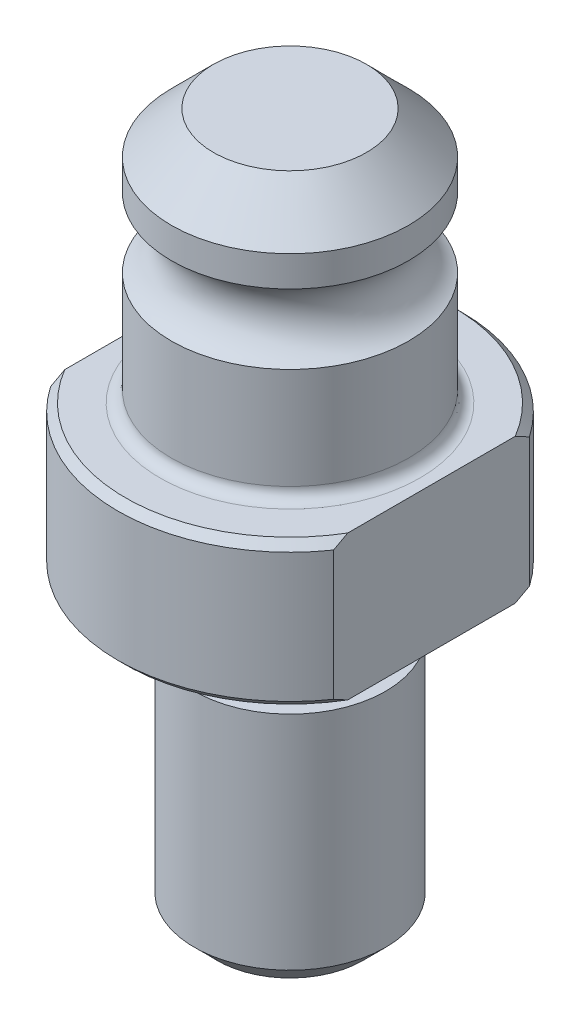
from build123d import *

# Parameters (mm, degrees)
CHAMFER1_SIZE      = 0.508
CHAMFER2_SIZE      = 1.524
CUT_EXTRUDE1_DEPTH = 30.6672
FILLET1_R          = 0.762


with BuildPart() as part:
    # Sketch1 → Revolve1 (revolve)
    with BuildSketch(Plane.XY):
        with BuildLine():
            Line((0, 26.543), (0, -20.066))
            Line((0, -20.066), (-6.35, -20.066))
            Line((-6.35, -20.066), (-6.35, -3.81))
            Line((-6.35, -3.81), (-5.1943, -3.81))
            Line((-5.1943, -3.81), (-5.1943, -1.27))
            ThreePointArc((-5.1943, -1.27), (-5.566274388, -0.371974388), (-6.4643, 0))
            Line((-6.4643, 0), (-11.43, 0))
            Line((-11.43, 0), (-11.43, 9.6012))
            Line((-11.43, 9.6012), (-7.874, 9.6012))
            Line((-7.874, 9.6012), (-7.874, 17.0942))
            ThreePointArc((-7.874, 17.0942), (-6.35, 19.4056), (-7.874, 21.717))
            Line((-7.874, 21.717), (-7.874, 23.749))
            Line((-7.874, 23.749), (-5.08, 26.543))
            Line((-5.08, 26.543), (0, 26.543))
        make_face()
    revolve(axis=Axis((0, -20.066, 0), (0, -1, 0)))

    # Chamfer1
    chamfer1_edges = [part.edges().sort_by_distance(p)[0] for p in [
        (11.43, 9.6012, 0),
        (11.43, 0, 0),
    ]]
    chamfer(chamfer1_edges, length=CHAMFER1_SIZE)

    # Chamfer2
    chamfer2_edges = [part.edges().sort_by_distance(p)[0] for p in [
        (6.35, -20.066, 0),
    ]]
    chamfer(chamfer2_edges, length=CHAMFER2_SIZE)

    # Sketch2 → Cut-Extrude1 (cut, through all)
    with BuildSketch(Plane(origin=(0, 9.6012, 0), x_dir=(1, 0, 0), z_dir=(0, 1, 0))):
        with BuildLine():
            Line((-9.398, 6.505574225), (-9.398, -6.505574225))
            ThreePointArc((-9.398, -6.505574225), (-11.43, 0), (-9.398, 6.505574225))
        make_face()
        with BuildLine():
            Line((9.398, 6.505574225), (9.398, -6.505574225))
            ThreePointArc((9.398, -6.505574225), (11.43, 0), (9.398, 6.505574225))
        make_face()
    extrude(amount=-CUT_EXTRUDE1_DEPTH, mode=Mode.SUBTRACT)

    # Fillet1
    fillet1_edges = [part.edges().sort_by_distance(p)[0] for p in [
        (7.874, 9.6012, 0),
    ]]
    fillet(fillet1_edges, radius=FILLET1_R)


solid = part.part
